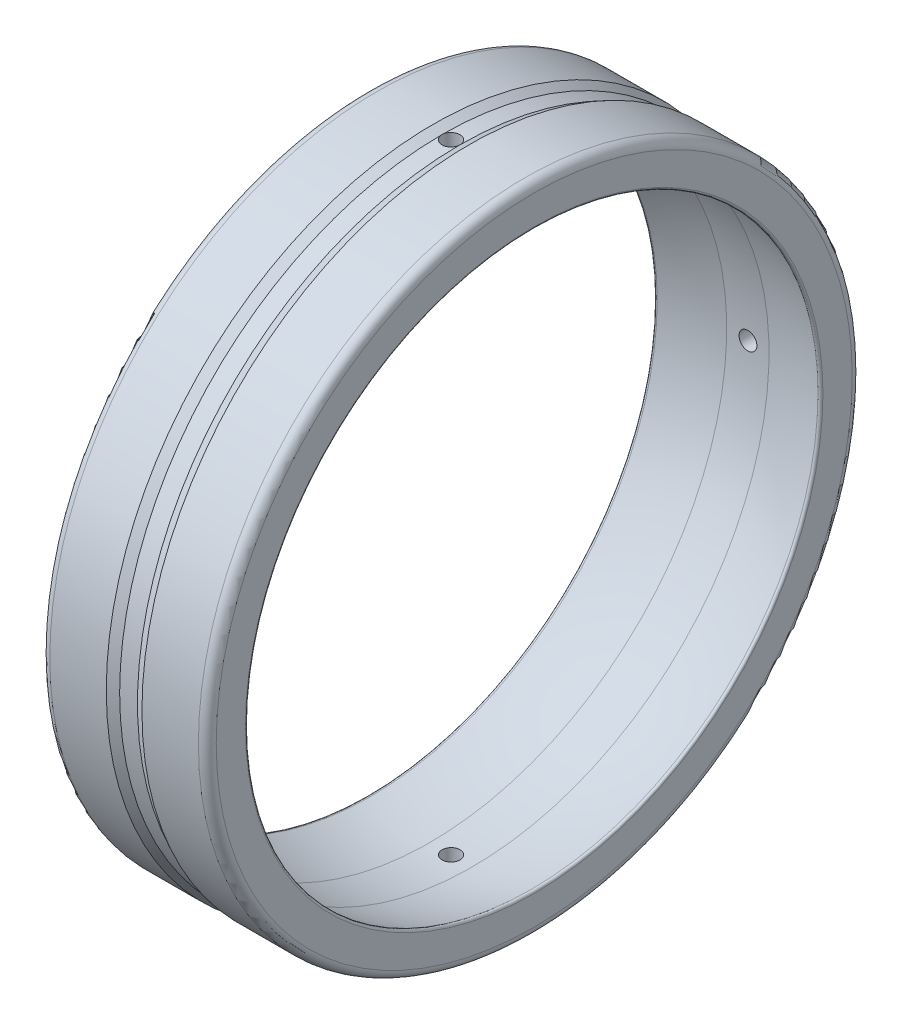
from build123d import *

# Parameters (mm, degrees)
SKETCH2_W = 1.5
SKETCH2_H = 6.75
SKETCH3_W = 1.5
SKETCH3_H = 6.75
SKETCH4_W = 1.5
SKETCH4_H = 6.75


with BuildPart() as part:
    # Sketch1 → Revolve1 (revolve)
    with BuildSketch(Plane.XY):
        with BuildLine():
            Line((28, 48.579004742), (28, 53.5))
            ThreePointArc((28, 53.5), (27.560660172, 54.560660172), (26.5, 55))
            Line((26.5, 55), (17, 55))
            Line((17, 55), (15.5, 54.25))
            Line((15.5, 54.25), (12.5, 54.25))
            Line((12.5, 54.25), (11, 55))
            Line((11, 55), (1.5, 55))
            ThreePointArc((1.5, 55), (0.439339828, 54.560660172), (0, 53.5))
            Line((0, 53.5), (0, 48.579004742))
            ThreePointArc((0, 48.579004742), (0.14856441, 48.28008682), (0.476543593, 48.218014577))
            ThreePointArc((0.476543593, 48.218014577), (5.413574266, 49.337927742), (10.439151002, 49.947891537))
            ThreePointArc((10.439151002, 49.947891537), (14, 49.966005785), (17.560848998, 49.947891537))
            ThreePointArc((17.560848998, 49.947891537), (22.586425734, 49.337927742), (27.523456407, 48.218014577))
            ThreePointArc((27.523456407, 48.218014577), (27.85143559, 48.28008682), (28, 48.579004742))
        make_face()
    revolve(axis=Axis((28, 0, 0), (-1, 0, 0)))

    # Sketch2 → Cut-Revolve1 (revolve, cut)
    with BuildSketch(Plane.XY):
        with Locations((14.75, -51.625)):
            Rectangle(SKETCH2_W, SKETCH2_H)
    revolve(axis=Axis((14, -55, 0), (0, 1, 0)), mode=Mode.SUBTRACT)

    # Sketch3 → Cut-Revolve2 (revolve, cut)
    with BuildSketch(Plane(origin=(0, 0, 0), x_dir=(1, 0, 0), z_dir=(0, 1, 0))):
        with Locations((14.75, 51.625)):
            Rectangle(SKETCH3_W, SKETCH3_H)
    revolve(axis=Axis((14, 0, -48.25), (0, 0, -1)), mode=Mode.SUBTRACT)

    # Sketch4 → Cut-Revolve3 (revolve, cut)
    with BuildSketch(Plane.XY):
        with Locations((14.75, 51.625)):
            Rectangle(SKETCH4_W, SKETCH4_H)
    revolve(axis=Axis((14, 48.25, 0), (0, 1, 0)), mode=Mode.SUBTRACT)


solid = part.part
